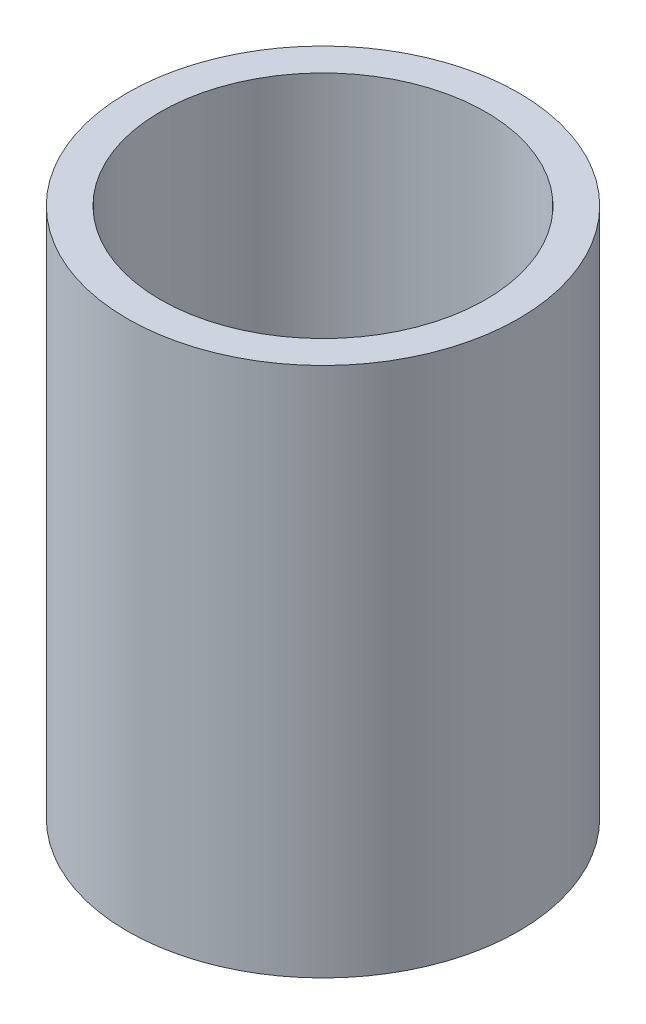
from build123d import *

# Parameters (mm, degrees)
SKETCH1_R           = 21.082
SKETCH1_R_2         = 17.526
BOSS_EXTRUDE1_DEPTH = 57.15


with BuildPart() as part:
    # Sketch1 → Boss-Extrude1 (new body)
    with BuildSketch(Plane(origin=(0, 0, 0), x_dir=(1, 0, 0), z_dir=(0, 1, 0))):
        Circle(SKETCH1_R)
        Circle(SKETCH1_R_2, mode=Mode.SUBTRACT)
    extrude(amount=BOSS_EXTRUDE1_DEPTH)


solid = part.part
